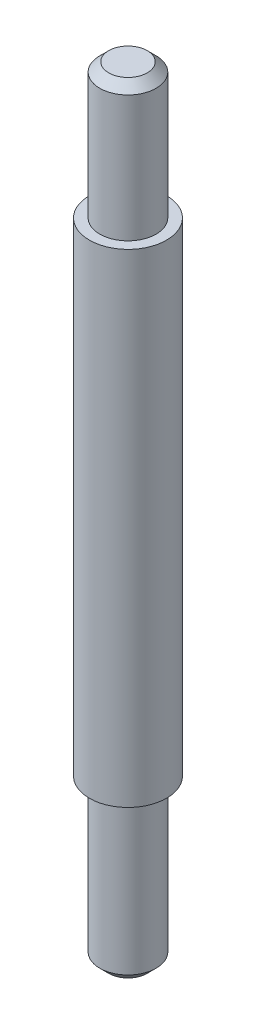
from build123d import *


with BuildPart() as part:
    # Sketch1 → Revolve1 (revolve)
    with BuildSketch(Plane.XY):
        Polygon((0, 127.107886558), (6.5, 127.107886558), (9.5, 124.107886558), (9.5, 81.5), (13, 81.5), (13, -81.5), (9.5, -81.5), (9.5, -132.892113442), (6.5, -135.892113442), (0, -135.892113442), align=None)
    revolve(axis=Axis((0, 127.107886558, 0), (0, -1, 0)))


solid = part.part
